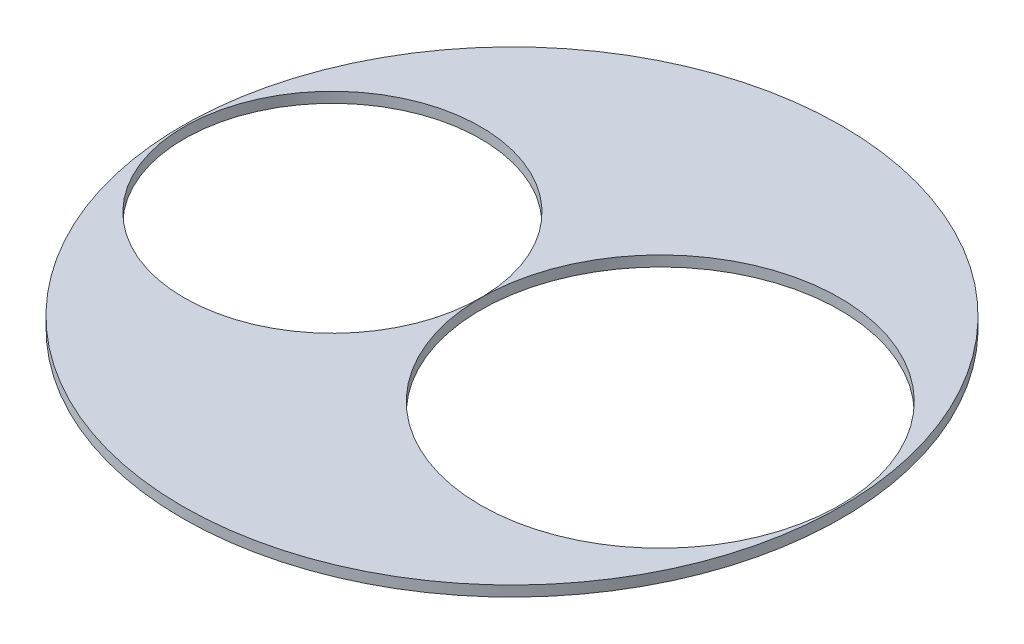
from build123d import *

# Parameters (mm, degrees)
SKETCH1_R           = 1200
SKETCH1_R_2         = 654.05
SKETCH1_R_3         = 539.75
BOSS_EXTRUDE1_DEPTH = 38.1


with BuildPart() as part:
    # Sketch1 → Boss-Extrude1 (new body)
    with BuildSketch(Plane(origin=(0, 0, 0), x_dir=(1, 0, 0), z_dir=(0, 1, 0))):
        Circle(SKETCH1_R)
        with Locations((539.876006559, 0)):
            Circle(SKETCH1_R_2, mode=Mode.SUBTRACT)
        with Locations((-653.949393441, 0)):
            Circle(SKETCH1_R_3, mode=Mode.SUBTRACT)
    extrude(amount=BOSS_EXTRUDE1_DEPTH)


solid = part.part
